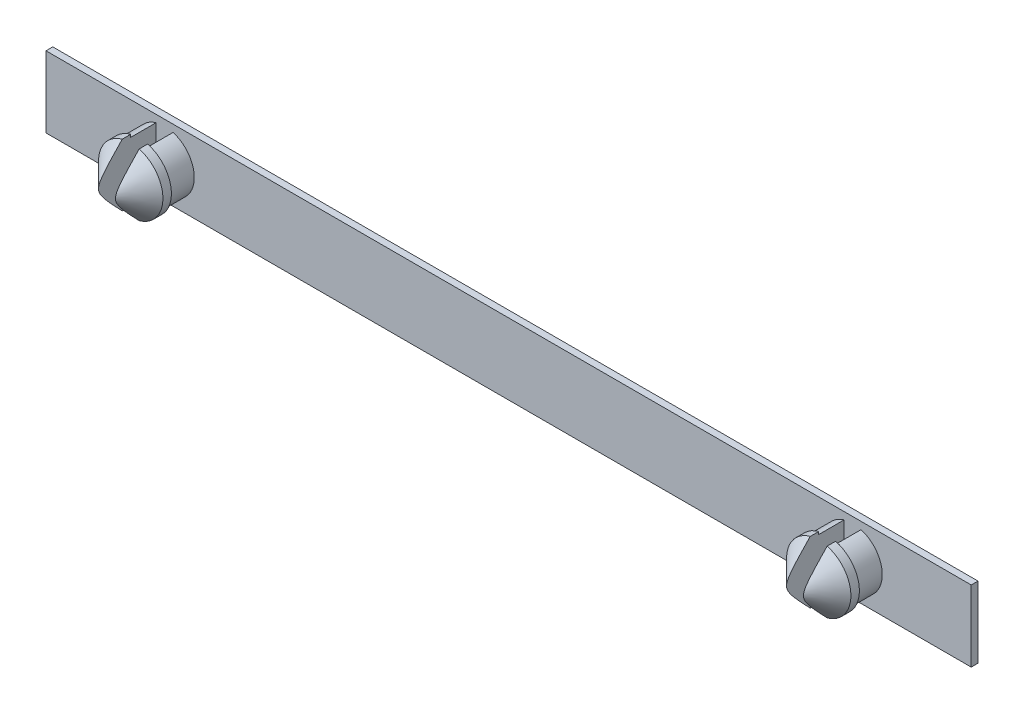
from build123d import *

# Parameters (mm, degrees)
SKICA2_W                 = 54.6
SKICA2_H                 = 4.2
P_IDAT_VYSUNUT_M2_DEPTH  = 0.4
SKICA3_R                 = 1.75
P_IDAT_VYSUNUT_M3_DEPTH  = 1.5
SKICA5_R                 = 1.9
P_IDAT_VYSUNUT_M5_DEPTH  = 2
ZKOSEN_2_SIZE            = 1.5
SKICA7_W                 = 1
SKICA7_H                 = 5
ODEBRAT_VYSUNUT_M1_DEPTH = 3.5


with BuildPart() as part:
    # Skica2 → Přidat vysunutím2 (new body)
    with BuildSketch(Plane.XY):
        Rectangle(SKICA2_W, SKICA2_H)
    extrude(amount=P_IDAT_VYSUNUT_M2_DEPTH)

    # Skica3 → Přidat vysunutím3 (add)
    with BuildSketch(Plane.XY.offset(0.4)):
        with Locations((-20.3, 0)):
            Circle(SKICA3_R)
        with Locations((20.3, 0)):
            Circle(SKICA3_R)
    extrude(amount=P_IDAT_VYSUNUT_M3_DEPTH)

    # Skica5 → Přidat vysunutím5 (add)
    with BuildSketch(Plane.XY.offset(1.9)):
        with Locations((-20.3, 0)):
            Circle(SKICA5_R)
        with Locations((20.3, 0)):
            Circle(SKICA5_R)
    extrude(amount=P_IDAT_VYSUNUT_M5_DEPTH)

    # Zkosení2
    zkosen_2_edges = [part.edges().sort_by_distance(p)[0] for p in [
        (-22.2, 0, 3.9),
        (18.4, 0, 3.9),
    ]]
    chamfer(zkosen_2_edges, length=ZKOSEN_2_SIZE)

    # Skica7 → Odebrat vysunutím1 (cut)
    with BuildSketch(Plane.XY.offset(3.9)):
        with Locations((-20.3, 0)):
            Rectangle(SKICA7_W, SKICA7_H)
        with Locations((20.3, 0)):
            Rectangle(SKICA7_W, SKICA7_H)
    extrude(amount=-ODEBRAT_VYSUNUT_M1_DEPTH, mode=Mode.SUBTRACT)


solid = part.part
